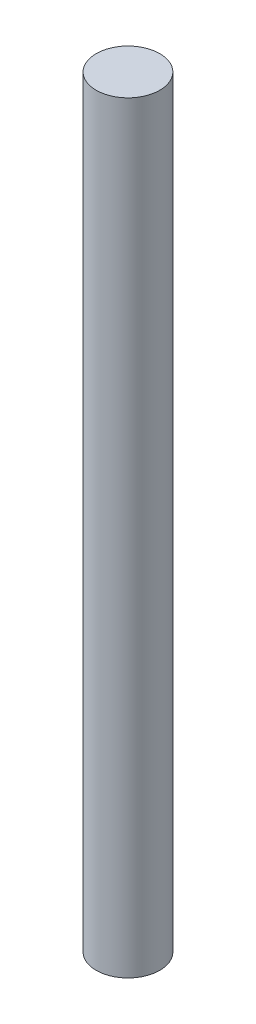
from build123d import *

# Parameters (mm, degrees)
ESBO_O1_R                = 5
RESSALTO_EXTRUS_O1_DEPTH = 120


with BuildPart() as part:
    # Esboço1 → Ressalto-extrusão1 (new body)
    with BuildSketch(Plane(origin=(0, 0, 0), x_dir=(1, 0, 0), z_dir=(0, 1, 0))):
        Circle(ESBO_O1_R)
    extrude(amount=RESSALTO_EXTRUS_O1_DEPTH)


solid = part.part
